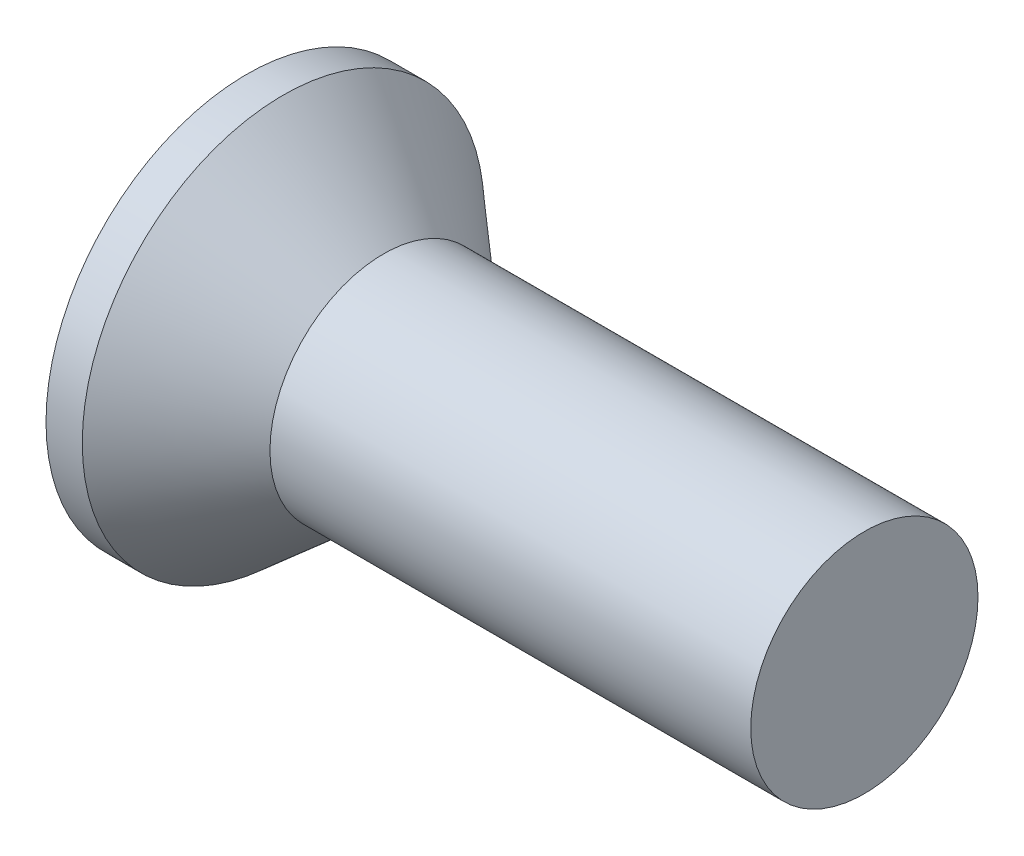
from build123d import *

# Parameters (mm, degrees)
SKETCH3_W         = 0.9652
SKETCH3_H         = 4.953
SKETCH4_W         = 0.4826
SKETCH4_H         = 0.4826
CIRPATTERN1_COUNT = 2
CIRPATTERN1_ANGLE = 90


with BuildPart() as part:
    # BodySke → Base-Revolve (revolve)
    with BuildSketch(Plane.XY):
        Polygon((0, 0), (0, 3.0988), (0.55957405, 3.0988), (2.1082, 1.7526), (9.525, 1.7526), (9.525, 0), align=None)
    revolve(axis=Axis((-6.35, 0, 0), (1, 0, 0)))

    # Sketch3 → Cross section 0
    with BuildSketch(Plane.ZY):
        Rectangle(SKETCH3_W, SKETCH3_H)
    # Sketch4 → Cross section 1
    with BuildSketch(Plane.ZY.offset(-2.8702)):
        Rectangle(SKETCH4_W, SKETCH4_H)
    cross = loft(mode=Mode.SUBTRACT)

    # CirPattern1: Cross ×2 about axis
    cirpattern1_axis = Axis((0, 0, 0), (1, 0, 0))
    for i in range(1, CIRPATTERN1_COUNT):
        add(cross.rotate(cirpattern1_axis, i * CIRPATTERN1_ANGLE / (CIRPATTERN1_COUNT - 1)), mode=Mode.SUBTRACT)


solid = part.part
